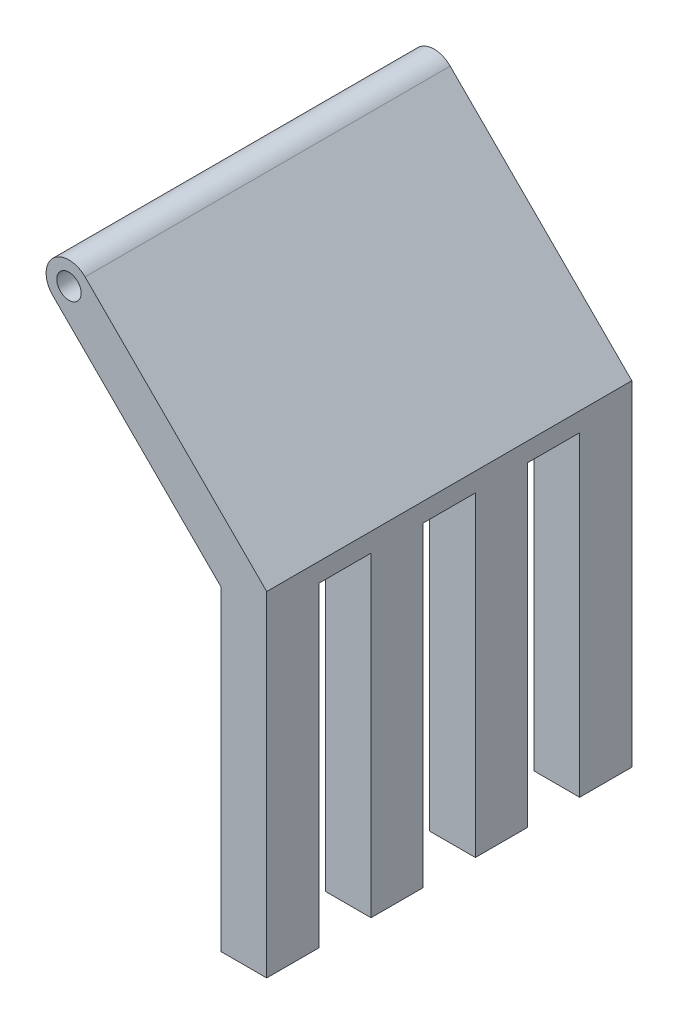
from build123d import *

# Parameters (mm, degrees)
SKETCH1_R           = 2
BOSS_EXTRUDE1_DEPTH = 60
SKETCH2_W           = 8.571428572
SKETCH2_H           = 51.893398282
CUT_EXTRUDE1_DEPTH  = 8.5


with BuildPart() as part:
    # Sketch1 → Boss-Extrude1 (new body)
    with BuildSketch(Plane.XY):
        with BuildLine():
            Line((0, 0), (0, 51.893398282))
            Line((0, 51.893398282), (-27.651650429, 79.545048712))
            ThreePointArc((-27.651650429, 79.545048712), (-27.651650429, 84.848349571), (-22.348349571, 84.848349571))
            Line((-22.348349571, 84.848349571), (7.5, 55))
            Line((7.5, 55), (7.5, 0))
            Line((7.5, 0), (0, 0))
        make_face()
        with Locations((-25, 82.196699141)):
            Circle(SKETCH1_R, mode=Mode.SUBTRACT)
    extrude(amount=BOSS_EXTRUDE1_DEPTH)

    # Sketch2 → Cut-Extrude1 (cut, through all)
    with BuildSketch(Plane.ZY):
        with Locations((30, 25.946699141)):
            Rectangle(SKETCH2_W, SKETCH2_H)
        with Locations((47.142857143, 25.946699141)):
            Rectangle(SKETCH2_W, SKETCH2_H)
        with Locations((12.857142857, 25.946699141)):
            Rectangle(SKETCH2_W, SKETCH2_H)
    extrude(amount=-CUT_EXTRUDE1_DEPTH, mode=Mode.SUBTRACT)


solid = part.part
